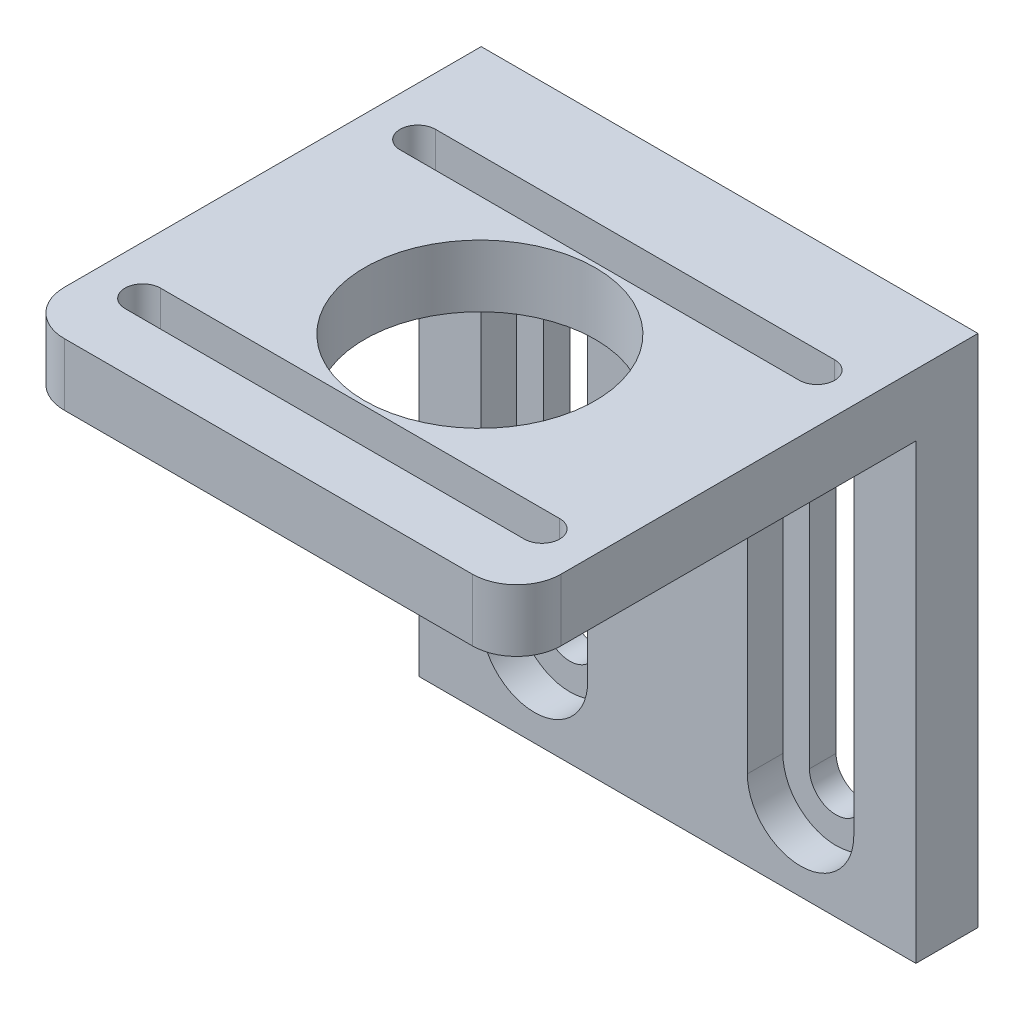
from build123d import *

# Parameters (mm, degrees)
ESBO_O1_W                  = 56
ESBO_O1_H                  = 58
RESSALTO_EXTRUS_O1_DEPTH   = 7
CORTE_EXTRUS_O1_DEPTH      = 7
ESBO_O4_W                  = 56
ESBO_O4_H                  = 7
RESSALTO_EXTRUS_O2_DEPTH   = 45
ESBO_O5_R                  = 13
ESBO_O5_R_2                = 2
CORTE_EXTRUS_O2_DEPTH      = 45
CORTE_EXTRUS_O3_DEPTH      = 2
CORTE_EXTRUS_O3_DEPTH_BACK = 4
FILETE1_R                  = 5
CORTE_EXTRUS_O4_DEPTH      = 10


with BuildPart() as part:
    # Esboço1 → Ressalto-extrusão1 (new body)
    with BuildSketch(Plane.XY):
        with Locations((-35.670310893, 154.468429513)):
            Rectangle(ESBO_O1_W, ESBO_O1_H)
    extrude(amount=RESSALTO_EXTRUS_O1_DEPTH)

    # Esboço3 → Corte-extrusão1 (cut)
    with BuildSketch(Plane.XY.offset(7)):
        with BuildLine():
            Line((-47.670310893, 134.468429513), (-47.670310893, 171.468429513))
            ThreePointArc((-47.670310893, 171.468429513), (-47.867793816, 172.538895782), (-48.434242916, 173.468429513))
            ThreePointArc((-48.434242916, 173.468429513), (-49.445566022, 174.2070423), (-50.670310893, 174.468429513))
            ThreePointArc((-50.670310893, 174.468429513), (-51.895055765, 174.2070423), (-52.906378871, 173.468429513))
            ThreePointArc((-52.906378871, 173.468429513), (-53.47282797, 172.538895782), (-53.670310893, 171.468429513))
            Line((-53.670310893, 171.468429513), (-53.670310893, 134.468429513))
            ThreePointArc((-53.670310893, 134.468429513), (-50.670310893, 131.468429513), (-47.670310893, 134.468429513))
        make_face()
        with BuildLine():
            Line((-23.670310893, 171.468429513), (-23.670310893, 134.468429513))
            ThreePointArc((-23.670310893, 134.468429513), (-20.670310893, 131.468429513), (-17.670310893, 134.468429513))
            Line((-17.670310893, 134.468429513), (-17.670310893, 171.468429513))
            ThreePointArc((-17.670310893, 171.468429513), (-17.867793816, 172.538895782), (-18.434242916, 173.468429513))
            ThreePointArc((-18.434242916, 173.468429513), (-19.445566022, 174.2070423), (-20.670310893, 174.468429513))
            ThreePointArc((-20.670310893, 174.468429513), (-21.895055765, 174.2070423), (-22.906378871, 173.468429513))
            ThreePointArc((-22.906378871, 173.468429513), (-23.47282797, 172.538895782), (-23.670310893, 171.468429513))
        make_face()
    extrude(amount=-CORTE_EXTRUS_O1_DEPTH, mode=Mode.SUBTRACT)

    # Esboço4 → Ressalto-extrusão2 (add)
    with BuildSketch(Plane.XY.offset(7)):
        with Locations((-35.670310893, 179.968429513)):
            Rectangle(ESBO_O4_W, ESBO_O4_H)
    extrude(amount=RESSALTO_EXTRUS_O2_DEPTH)

    # Esboço5 → Corte-extrusão2 (cut)
    with BuildSketch(Plane.XZ.offset(-176.468429513)):
        with Locations((-35.670310893, 28.15)):
            Circle(ESBO_O5_R)
        with Locations((-51.170310893, 43.65)):
            Circle(ESBO_O5_R_2)
        with Locations((-20.170310893, 43.65)):
            Circle(ESBO_O5_R_2)
        with Locations((-51.170310893, 12.65)):
            Circle(ESBO_O5_R_2)
        with Locations((-20.170310893, 12.65)):
            Circle(ESBO_O5_R_2)
    extrude(amount=-CORTE_EXTRUS_O2_DEPTH, mode=Mode.SUBTRACT)

    # Esboço6 → Corte-extrusão3 (cut, two sides)
    with BuildSketch(Plane.XY.offset(7)) as corte_extrus_o3_sk:
        with BuildLine():
            Line((-56.670310893, 171.468429513), (-56.670310893, 134.468429513))
            ThreePointArc((-56.670310893, 134.468429513), (-50.670310893, 128.468429513), (-44.670310893, 134.468429513))
            Line((-44.670310893, 134.468429513), (-44.670310893, 171.468429513))
            ThreePointArc((-44.670310893, 171.468429513), (-50.670310893, 177.468429513), (-56.670310893, 171.468429513))
        make_face()
        with BuildLine():
            Line((-14.670310893, 134.468429513), (-14.670310893, 171.468429513))
            ThreePointArc((-14.670310893, 171.468429513), (-20.670310893, 177.468429513), (-26.670310893, 171.468429513))
            Line((-26.670310893, 171.468429513), (-26.670310893, 134.468429513))
            ThreePointArc((-26.670310893, 134.468429513), (-20.670310893, 128.468429513), (-14.670310893, 134.468429513))
        make_face()
    extrude(amount=CORTE_EXTRUS_O3_DEPTH, mode=Mode.SUBTRACT)
    extrude(corte_extrus_o3_sk.sketch, amount=-CORTE_EXTRUS_O3_DEPTH_BACK, mode=Mode.SUBTRACT)

    # Filete1
    filete1_edges = [part.edges().sort_by_distance(p)[0] for p in [
        (-63.670310893, 179.968429513, 52),
        (-7.670310893, 179.968429513, 52),
    ]]
    fillet(filete1_edges, radius=FILETE1_R)

    # Esboço7 → Corte-extrusão4 (cut)
    with BuildSketch(Plane(origin=(0, 183.468429513, 0), x_dir=(1, 0, 0), z_dir=(0, 1, 0))):
        with BuildLine():
            Line((-58.170310893, -10.65), (-13.170310893, -10.65))
            ThreePointArc((-13.170310893, -10.65), (-11.170310893, -12.65), (-13.170310893, -14.65))
            Line((-13.170310893, -14.65), (-58.170310893, -14.65))
            ThreePointArc((-58.170310893, -14.65), (-60.170310893, -12.65), (-58.170310893, -10.65))
        make_face()
        with BuildLine():
            Line((-13.170310893, -45.65), (-58.170310893, -45.65))
            ThreePointArc((-58.170310893, -45.65), (-60.170310893, -43.65), (-58.170310893, -41.65))
            Line((-58.170310893, -41.65), (-13.170310893, -41.65))
            ThreePointArc((-13.170310893, -41.65), (-11.170310893, -43.65), (-13.170310893, -45.65))
        make_face()
    extrude(amount=-CORTE_EXTRUS_O4_DEPTH, mode=Mode.SUBTRACT)


solid = part.part
